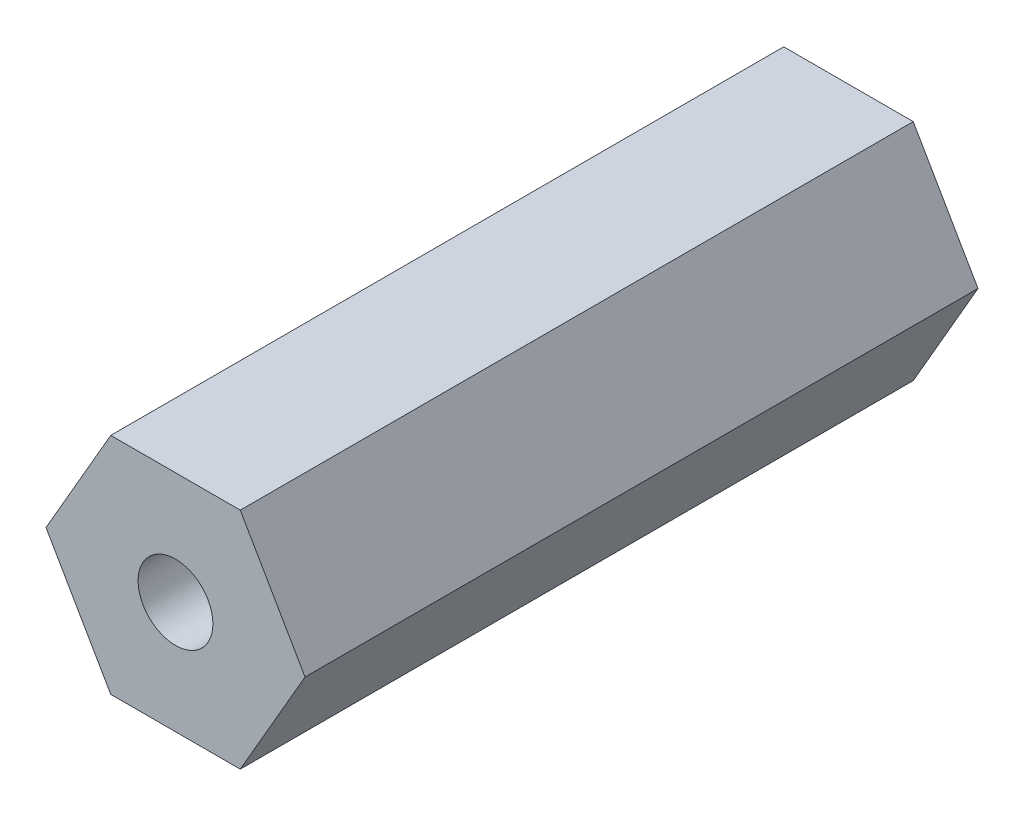
from build123d import *

# Parameters (mm, degrees)
SKETCH1_R           = 1
BOSS_EXTRUDE1_DEPTH = 18


with BuildPart() as part:
    # Sketch1 → Boss-Extrude1 (new body)
    with BuildSketch(Plane.XY):
        Polygon((3.464101615, 0), (1.732050808, 3), (-1.732050808, 3), (-3.464101615, 0), (-1.732050808, -3), (1.732050808, -3), align=None)
        Circle(SKETCH1_R, mode=Mode.SUBTRACT)
    extrude(amount=BOSS_EXTRUDE1_DEPTH)


solid = part.part
